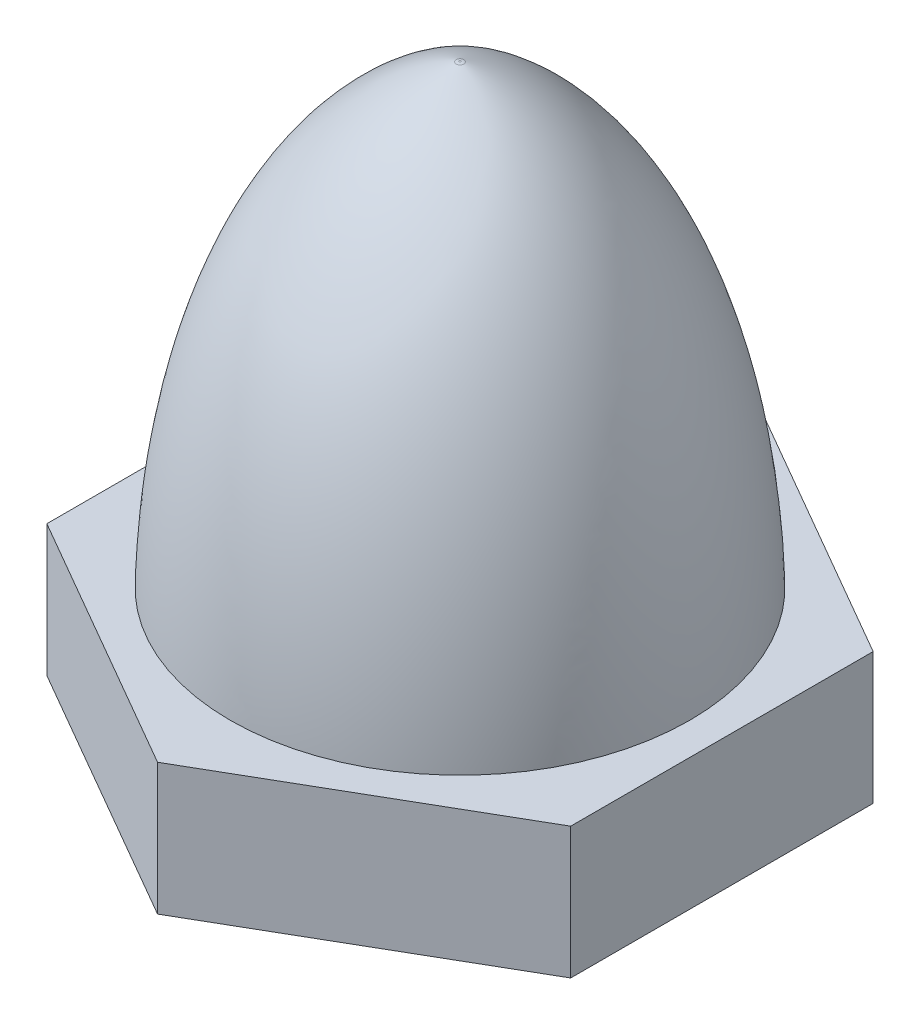
from build123d import *

# Parameters (mm, degrees)
SALIENTE_EXTRUIR1_DEPTH = 3
CROQUIS2_R              = 5.5
SALIENTE_EXTRUIR2_DEPTH = 10.4
REDONDEO3_R             = 0.2
CROQUIS4_R              = 2.5
CORTAR_EXTRUIR1_DEPTH   = 10


with BuildPart() as part:
    # Croquis1 → Saliente-Extruir1 (new body)
    with BuildSketch(Plane(origin=(0, 0, 0), x_dir=(1, 0, 0), z_dir=(0, 1, 0))):
        Polygon((0, -6.9), (5.975575286, -3.45), (5.975575286, 3.45), (0, 6.9), (-5.975575286, 3.45), (-5.975575286, -3.45), align=None)
    extrude(amount=SALIENTE_EXTRUIR1_DEPTH)

    # Croquis2 → Saliente-Extruir2 (add)
    with BuildSketch(Plane(origin=(0, 3, 0), x_dir=(1, 0, 0), z_dir=(0, 1, 0))):
        Circle(CROQUIS2_R)
    extrude(amount=SALIENTE_EXTRUIR2_DEPTH)

    # Croquis3 → Cortar-Revolución17 (revolve, cut)
    with BuildSketch(Plane(origin=(0, 0, 0), x_dir=(0.8660254037844386, 0, 0.5000000000000001), z_dir=(-0.5000000000000001, 0, 0.8660254037844386))):
        with BuildLine():
            Line((-0.05505313, 13.4), (-9.065705725, 13.4))
            Line((-9.065705725, 13.4), (-9.065705725, 3))
            Line((-9.065705725, 3), (-5.242775997, 3))
            add(Edge.make_bspline(
                [(-0.05505313, 13.4), (-3.55300642, 12.195542183), (-5.129402013, 7.591757737), (-5.242775997, 3)],
                knots=[0.003430867, 0.003430867, 0.003430867, 0.003430867, 0.878426724, 0.878426724, 0.878426724, 0.878426724], degree=3))
        make_face()
    revolve(axis=Axis((0, 16.4, 0), (0, -1, 0)), mode=Mode.SUBTRACT)

    # Redondeo3
    redondeo3_edges = [part.edges().sort_by_distance(p)[0] for p in [
        (0.04767741, 13.4, 0.027526565),
    ]]
    fillet(redondeo3_edges, radius=REDONDEO3_R)

    # Croquis4 → Cortar-Extruir1 (cut)
    with BuildSketch(Plane.XZ):
        Circle(CROQUIS4_R)
    extrude(amount=-CORTAR_EXTRUIR1_DEPTH, mode=Mode.SUBTRACT)


solid = part.part
